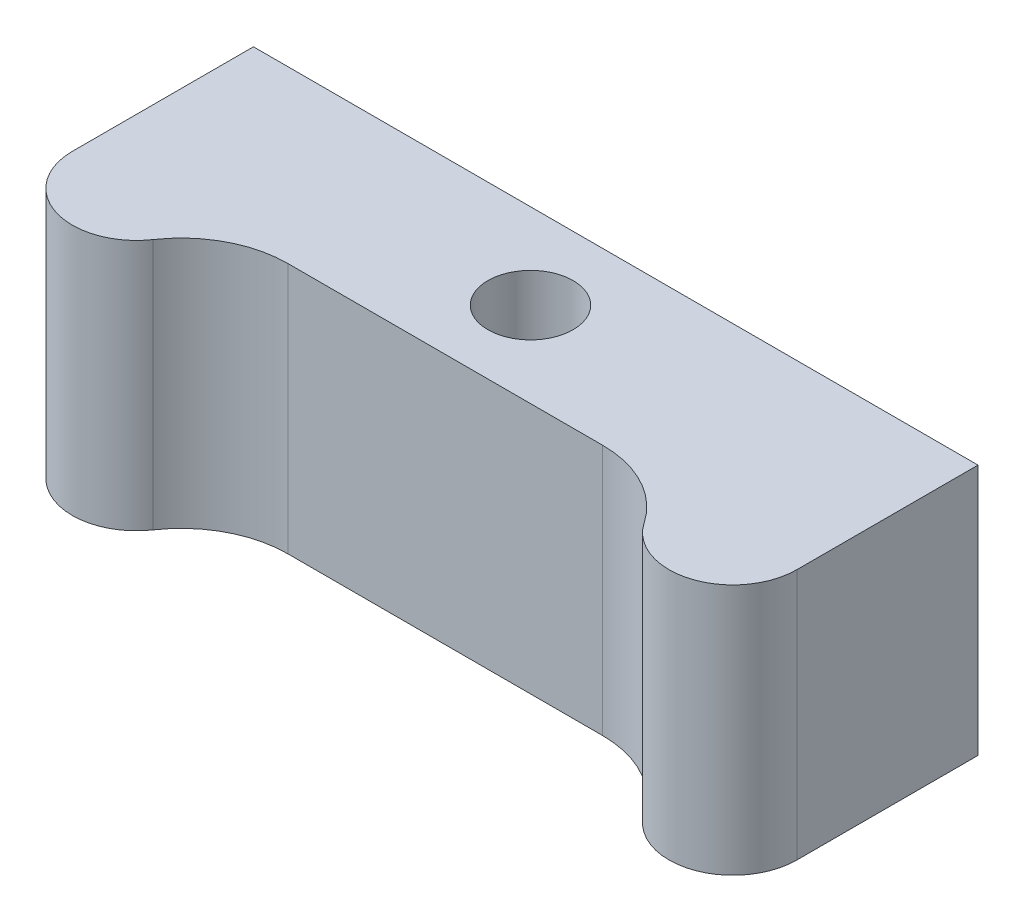
from build123d import *

# Parameters (mm, degrees)
BOSS_EXTRUDE1_DEPTH = 11.8
SKETCH2_R           = 2
CUT_EXTRUDE1_DEPTH  = 12.8


with BuildPart() as part:
    # Sketch1 → Boss-Extrude1 (new body)
    with BuildSketch(Plane(origin=(0, 0, 0), x_dir=(1, 0, 0), z_dir=(0, 1, 0))):
        with BuildLine():
            Line((7.385621722, -4), (-7.385621722, -4))
            ThreePointArc((-7.385621722, -4), (-9.724157589, -4.580582618), (-11.519608146, -6.1875))
            ThreePointArc((-11.519608146, -6.1875), (-14.882843258, -7.367156742), (-17, -4.5))
            Line((-17, -4.5), (-17, 4))
            Line((-17, 4), (17, 4))
            Line((17, 4), (17, -4.5))
            ThreePointArc((17, -4.5), (14.882843258, -7.367156742), (11.519608146, -6.1875))
            ThreePointArc((11.519608146, -6.1875), (9.724157589, -4.580582618), (7.385621722, -4))
        make_face()
    extrude(amount=BOSS_EXTRUDE1_DEPTH)

    # Sketch2 → Cut-Extrude1 (cut, through all)
    with BuildSketch(Plane(origin=(0, 11.8, 0), x_dir=(1, 0, 0), z_dir=(0, 1, 0))):
        Circle(SKETCH2_R)
    extrude(amount=-CUT_EXTRUDE1_DEPTH, mode=Mode.SUBTRACT)


solid = part.part
